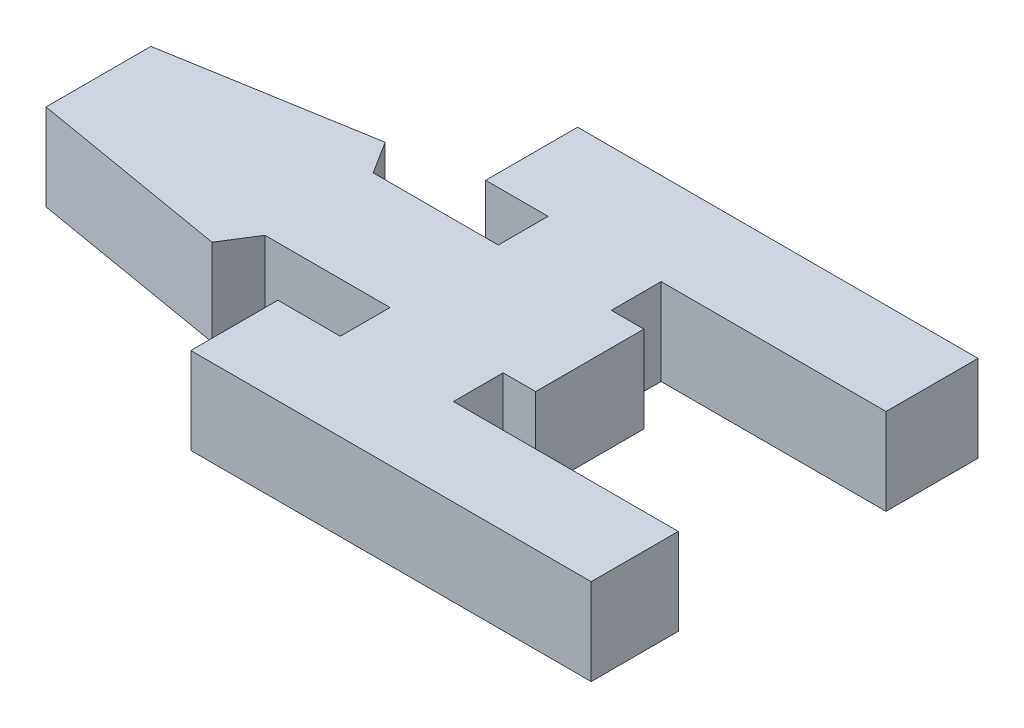
from build123d import *

# Parameters (mm, degrees)
BOSS_EXTRUDE1_DEPTH = 8
SKETCH2_R           = 2.5
BOSS_EXTRUDE2_DEPTH = 6


with BuildPart() as part:
    # Sketch1 → Boss-Extrude1 (new body)
    with BuildSketch(Plane(origin=(0, 0, 0), x_dir=(1, 0, 0), z_dir=(0, 1, 0))):
        Polygon((35.785540038, 49.619336569), (37.676406325, 46.619336569), (49.238802, 46.619336569), (49.238802, 51.219336569), (43.473118302, 51.219336569), (43.473118302, 59.719336569), (80.473118302, 59.719336569), (80.473118302, 51.219336569), (59.689103703, 51.219336569), (59.689103703, 46.619336569), (62.692063962, 46.619336569), (62.692063962, 36.619336569), (59.689103703, 36.619336569), (59.689103703, 32.019336569), (80.473118302, 32.019336569), (80.473118302, 23.971403073), (43.473118302, 23.971403073), (43.473118302, 32.019336569), (49.238802, 32.019336569), (49.238802, 36.619336569), (37.676406325, 36.619336569), (35.785540038, 33.619336569), (17.28730484, 36.774336569), (17.28730484, 46.466988702), align=None)
    extrude(amount=BOSS_EXTRUDE1_DEPTH)

    # Sketch2 → Boss-Extrude2 (add)
    with BuildSketch(Plane.XZ):
        with Locations((49.08730484, -41.619733902)):
            Circle(SKETCH2_R)
    extrude(amount=BOSS_EXTRUDE2_DEPTH)


solid = part.part
